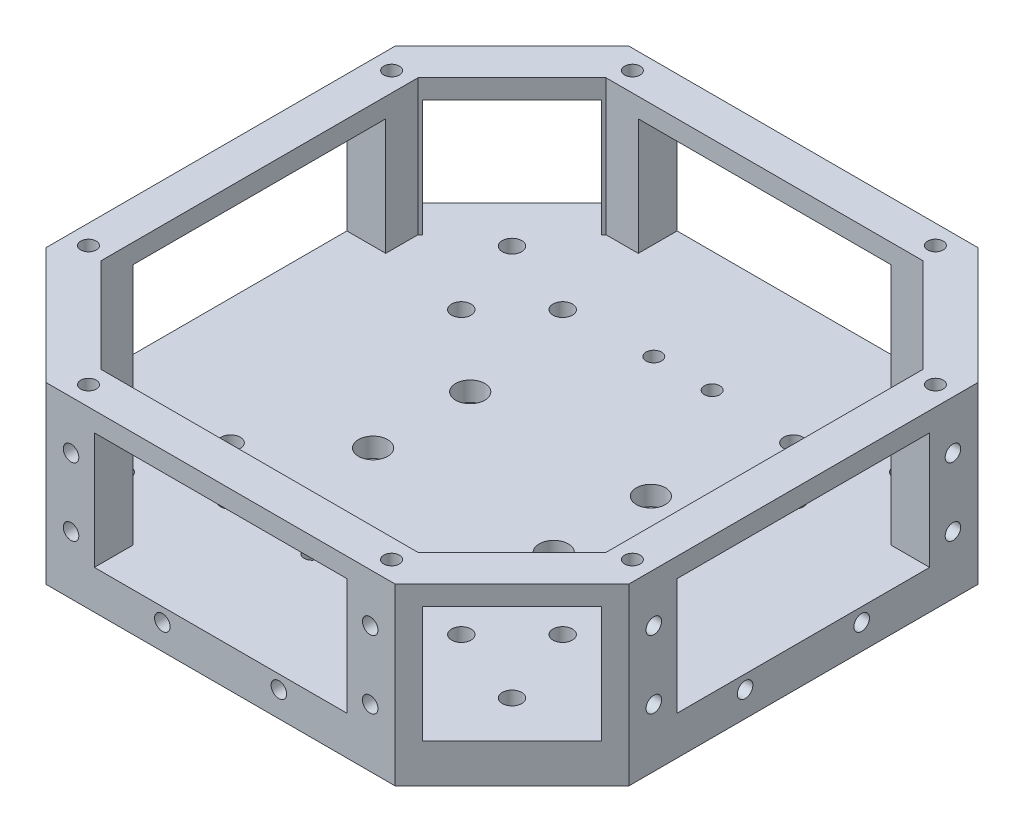
from build123d import *

# Parameters (mm, degrees)
BOSS_EXTRUDE1_DEPTH                     = 90
CUT_EXTRUDE2_DEPTH                      = 70
SKETCH6_W                               = 130
SKETCH6_H                               = 60
CUT_EXTRUDE3_DEPTH                      = 70
CIRPATTERN1_COUNT                       = 4
SKETCH7_W                               = 65
SKETCH7_H                               = 60
CUT_EXTRUDE4_DEPTH                      = 382.764068712
CIRPATTERN2_COUNT                       = 4
F_1_0MM_DOWEL_HOLE1_D                   = 10
F_1_0MM_DOWEL_HOLE2_D                   = 8
MIRROR2_COPY_1_D                        = 10
MIRROR2_COPY_2_D                        = 8
CBORE_FOR_M5_HEX_HEAD_BOLT1_D           = 8
CBORE_FOR_M5_HEX_HEAD_BOLT1_CBORE_D     = 15
CBORE_FOR_M5_HEX_HEAD_BOLT1_CBORE_DEPTH = 10
F_1_0MM_DOWEL_HOLE5_D                   = 8
F_1_0MM_DOWEL_HOLE5_DEPTH               = 20
F_1_0MM_DOWEL_HOLE10_D                  = 8
F_1_0MM_DOWEL_HOLE10_DEPTH              = 10
F_1_0MM_DOWEL_HOLE11_D                  = 8
F_1_0MM_DOWEL_HOLE11_DEPTH              = 10


with BuildPart() as part:
    # Sketch1 → Boss-Extrude1 (new body)
    with BuildSketch(Plane(origin=(0, 0, 0), x_dir=(1, 0, 0), z_dir=(0, 1, 0))):
        Polygon((-150, 89.895923599), (-89.895923599, 150), (89.895923599, 150), (150, 89.895923599), (150, -89.895923599), (89.895923599, -150), (-89.895923599, -150), (-150, -89.895923599), align=None)
    extrude(amount=BOSS_EXTRUDE1_DEPTH)

    # Sketch2 → Cut-Extrude2 (cut)
    with BuildSketch(Plane(origin=(0, 90, 0), x_dir=(1, 0, 0), z_dir=(0, 1, 0))):
        Polygon((-130, -81.611652352), (-130, 81.611652352), (-81.611652352, 130), (81.611652352, 130), (130, 81.611652352), (130, -81.611652352), (81.611652352, -130), (-81.611652352, -130), align=None)
    extrude(amount=-CUT_EXTRUDE2_DEPTH, mode=Mode.SUBTRACT)

    # Sketch6 → Cut-Extrude3 (cut)
    with BuildSketch(Plane(origin=(150, 0, 0), x_dir=(0, 0, -1), z_dir=(1, 0, 0))):
        with Locations((0, 50)):
            Rectangle(SKETCH6_W, SKETCH6_H)
    cut_extrude3 = extrude(amount=-CUT_EXTRUDE3_DEPTH, mode=Mode.SUBTRACT)

    # CirPattern1: Cut-Extrude3 ×4 about axis
    cirpattern1_axis = Axis((0, 0, 0), (0, 1, 0))
    for i in range(1, CIRPATTERN1_COUNT):
        add(cut_extrude3.rotate(cirpattern1_axis, i * 360 / CIRPATTERN1_COUNT), mode=Mode.SUBTRACT)

    # Sketch7 → Cut-Extrude4 (cut, through all)
    with BuildSketch(Plane(origin=(119.9479618, 0, 119.9479618), x_dir=(0.707106781, 0, -0.707106781), z_dir=(0.707106781, 0, 0.707106781))):
        with Locations((0, 50)):
            Rectangle(SKETCH7_W, SKETCH7_H)
    cut_extrude4 = extrude(amount=-CUT_EXTRUDE4_DEPTH, mode=Mode.SUBTRACT)

    # CirPattern2: Cut-Extrude4 ×4 about axis
    cirpattern2_axis = Axis((0, 20, 0), (0, -1, 0))
    for i in range(1, CIRPATTERN2_COUNT):
        add(cut_extrude4.rotate(cirpattern2_axis, i * 360 / CIRPATTERN2_COUNT), mode=Mode.SUBTRACT)

    # Ø1.0mm Dowel Hole1 (through all)
    with Locations(Plane(origin=(0, 20, 0), x_dir=(1, 0, 0), z_dir=(0, 1, 0))):
        with Locations((-100.72, -100.72), (-85.48, -59.39), (-59.39, -85.48)):
            f_1_0mm_dowel_hole1 = Hole(F_1_0MM_DOWEL_HOLE1_D / 2)

    # Ø1.0mm Dowel Hole2 (through all)
    with Locations(Plane(origin=(0, 20, 0), x_dir=(1, 0, 0), z_dir=(0, 1, 0))):
        with Locations((-15.01, -88)):
            f_1_0mm_dowel_hole2 = Hole(F_1_0MM_DOWEL_HOLE2_D / 2)

    # Mirror1: Ø1.0mm Dowel Hole1, Ø1.0mm Dowel Hole2 across plane
    add(f_1_0mm_dowel_hole1.mirror(Plane.XY), mode=Mode.SUBTRACT)
    add(f_1_0mm_dowel_hole2.mirror(Plane.XY), mode=Mode.SUBTRACT)

    # Mirror2: Ø1.0mm Dowel Hole1, Ø1.0mm Dowel Hole2 across plane
    add(f_1_0mm_dowel_hole1.mirror(Plane(origin=(0, 0, 0), x_dir=(0, 0, 1), z_dir=(1, 0, 0))), mode=Mode.SUBTRACT)
    add(f_1_0mm_dowel_hole2.mirror(Plane(origin=(0, 0, 0), x_dir=(0, 0, 1), z_dir=(1, 0, 0))), mode=Mode.SUBTRACT)

    # Mirror2 copy 1 (through all)
    with Locations(Plane(origin=(0, 20, 0), x_dir=(-1, 0, 0), z_dir=(0, 1, 0))):
        with Locations((-100.72, -100.72), (-85.48, -59.39), (-59.39, -85.48)):
            Hole(MIRROR2_COPY_1_D / 2)

    # Mirror2 copy 2 (through all)
    with Locations(Plane(origin=(0, 20, 0), x_dir=(-1, 0, 0), z_dir=(0, 1, 0))):
        with Locations((-15.01, -88)):
            Hole(MIRROR2_COPY_2_D / 2)

    # CBORE for M5 Hex Head Bolt1 (through all)
    with Locations(Plane(origin=(0, 20, 0), x_dir=(1, 0, 0), z_dir=(0, 1, 0))):
        with Locations((-46.51, -25.01), (46.49, -25.01)):
            cbore_for_m5_hex_head_bolt1 = CounterBoreHole(CBORE_FOR_M5_HEX_HEAD_BOLT1_D / 2, CBORE_FOR_M5_HEX_HEAD_BOLT1_CBORE_D / 2, CBORE_FOR_M5_HEX_HEAD_BOLT1_CBORE_DEPTH)

    # Mirror3: CBORE for M5 Hex Head Bolt1 across plane
    add(cbore_for_m5_hex_head_bolt1.mirror(Plane.XY), mode=Mode.SUBTRACT)

    # Ø1.0mm Dowel Hole5
    with Locations(Plane(origin=(0, 90, 0), x_dir=(1, 0, 0), z_dir=(0, 1, 0))):
        with Locations((-140.01, -78.01), (-78.01, -140.01), (77.99, -140.01), (139.99, -78.01)):
            f_1_0mm_dowel_hole5 = Hole(F_1_0MM_DOWEL_HOLE5_D / 2, depth=F_1_0MM_DOWEL_HOLE5_DEPTH)

    # Mirror4: Ø1.0mm Dowel Hole5 across plane
    add(f_1_0mm_dowel_hole5.mirror(Plane.XY), mode=Mode.SUBTRACT)

    # Ø1.0mm Dowel Hole10
    with Locations(Plane(origin=(150, 0, 0), x_dir=(0, 0, -1), z_dir=(1, 0, 0))):
        with Locations((-77, 65), (-77, 30), (-30, 13), (30, 13), (77, 30), (77, 65)):
            f_1_0mm_dowel_hole10 = Hole(F_1_0MM_DOWEL_HOLE10_D / 2, depth=F_1_0MM_DOWEL_HOLE10_DEPTH)

    # Mirror5: Ø1.0mm Dowel Hole10 across plane
    add(f_1_0mm_dowel_hole10.mirror(Plane(origin=(0, 0, 0), x_dir=(0, 0, 1), z_dir=(1, 0, 0))), mode=Mode.SUBTRACT)

    # Ø1.0mm Dowel Hole11
    with Locations(Plane.XY.offset(150)):
        with Locations((-77, 65), (-77, 30), (-30, 13), (30, 13), (77, 30), (77, 65)):
            f_1_0mm_dowel_hole11 = Hole(F_1_0MM_DOWEL_HOLE11_D / 2, depth=F_1_0MM_DOWEL_HOLE11_DEPTH)

    # Mirror6: Ø1.0mm Dowel Hole11 across plane
    add(f_1_0mm_dowel_hole11.mirror(Plane.XY), mode=Mode.SUBTRACT)


solid = part.part
